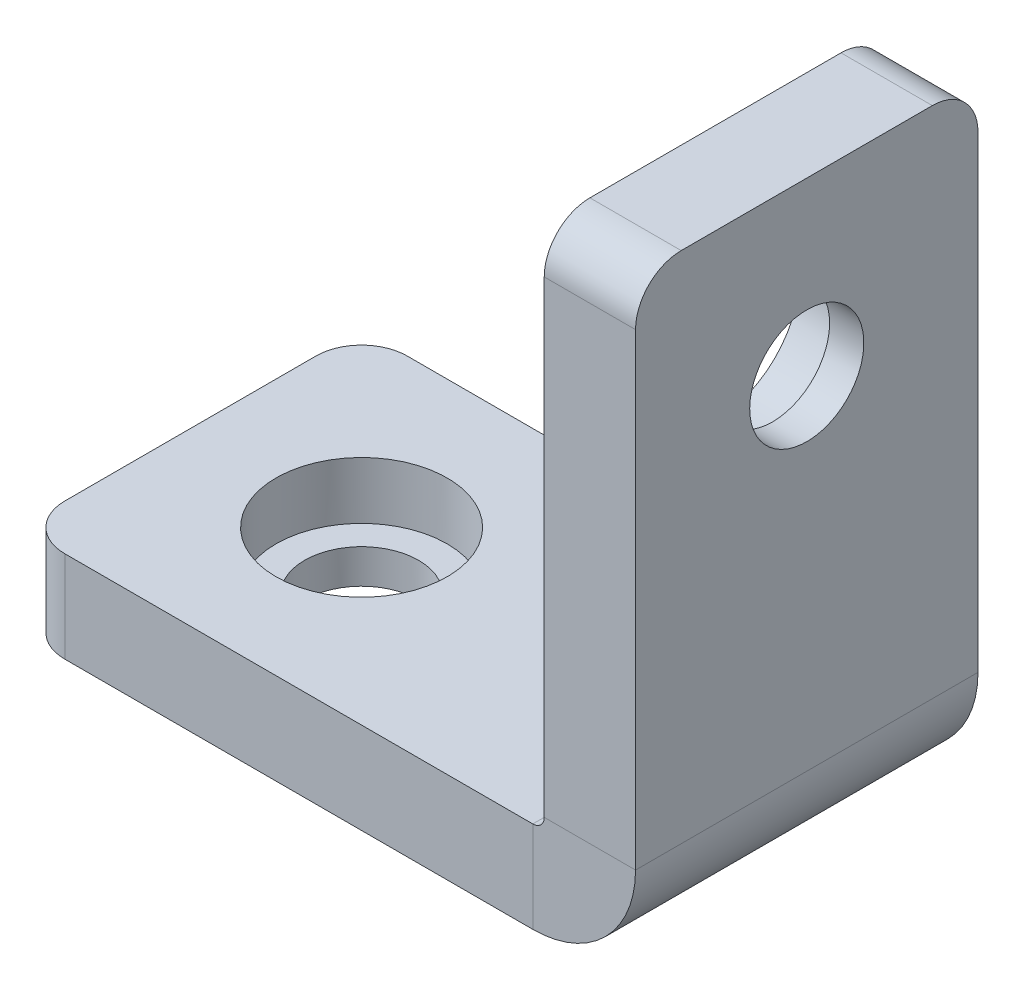
from build123d import *

# Parameters (mm, degrees)
SKETCH5_W          = 15
SKETCH5_H          = 4
SKETCH7_R          = 2.5
CUT_EXTRUDE2_DEPTH = 5
FILLET1_R          = 2
SKETCH9_R          = 3.7
CUT_EXTRUDE3_DEPTH = 2.5
SKETCH6_R          = 2.5
CUT_EXTRUDE4_DEPTH = 5
SKETCH10_R         = 3.75
CUT_EXTRUDE5_DEPTH = 2.5


with BuildPart() as part:
    # Sweep1: sweep along a path in Sketch2
    with BuildLine(Plane.XY) as sweep1_path:
        Line((-25, 0), (-2.5, 0))
        ThreePointArc((-2.5, 0), (-0.732233047, 0.732233047), (0, 2.5))
        Line((0, 2.5), (0, 25))
    # Sketch5 → Sweep1 (sweep)
    with BuildSketch(Plane(origin=(-25, 0, 0), x_dir=(0, 0, -1), z_dir=(1, 0, 0))):
        Rectangle(SKETCH5_W, SKETCH5_H)
    sweep(path=sweep1_path.line)

    # Sketch7 → Cut-Extrude2 (cut, through all)
    with BuildSketch(Plane.ZY.offset(2)):
        with Locations((0, 17.5)):
            Circle(SKETCH7_R)
    extrude(amount=-CUT_EXTRUDE2_DEPTH, mode=Mode.SUBTRACT)

    # Fillet1
    fillet1_edges = [part.edges().sort_by_distance(p)[0] for p in [
        (-25, 0, 7.5),
        (0, 25, -7.5),
        (0, 25, 7.5),
        (-25, 0, -7.5),
    ]]
    fillet(fillet1_edges, radius=FILLET1_R)

    # Sketch9 → Cut-Extrude3 (cut)
    with BuildSketch(Plane.ZY.offset(2)):
        with Locations((0, 17.5)):
            Circle(SKETCH9_R)
    extrude(amount=-CUT_EXTRUDE3_DEPTH, mode=Mode.SUBTRACT)

    # Sketch6 → Cut-Extrude4 (cut, through all)
    with BuildSketch(Plane(origin=(0, 2, 0), x_dir=(1, 0, 0), z_dir=(0, 1, 0))):
        with Locations((-17.5, 0)):
            Circle(SKETCH6_R)
    extrude(amount=-CUT_EXTRUDE4_DEPTH, mode=Mode.SUBTRACT)

    # Sketch10 → Cut-Extrude5 (cut)
    with BuildSketch(Plane(origin=(0, 2, 0), x_dir=(1, 0, 0), z_dir=(0, 1, 0))):
        with Locations((-17.5, 0)):
            Circle(SKETCH10_R)
    extrude(amount=-CUT_EXTRUDE5_DEPTH, mode=Mode.SUBTRACT)


solid = part.part
